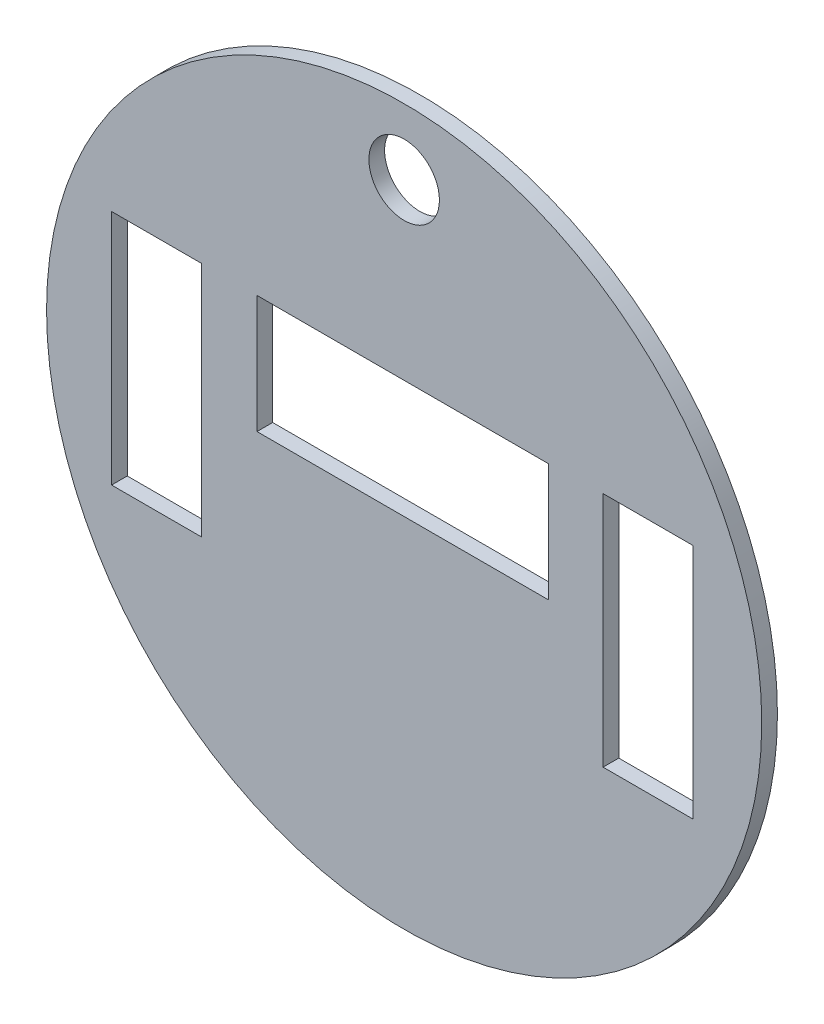
from build123d import *

# Parameters (mm, degrees)
SKETCH1_R           = 312.497780416
SKETCH1_R_2         = 30.815082176
SKETCH1_W           = 78.780158854
SKETCH1_H           = 207.033394325
SKETCH1_H_2         = 207.033394324
SKETCH1_W_2         = 254.787899309
SKETCH1_H_3         = 103.031623715
BOSS_EXTRUDE1_DEPTH = 13.716


with BuildPart() as part:
    # Sketch1 → Boss-Extrude1 (new body)
    with BuildSketch(Plane.XY):
        Circle(SKETCH1_R)
        with Locations((0, 254.843469114)):
            Circle(SKETCH1_R_2, mode=Mode.SUBTRACT)
        with Locations((213.217227107, 0.764216519)):
            Rectangle(SKETCH1_W, SKETCH1_H, mode=Mode.SUBTRACT)
        with Locations((-216.277951012, -0.485073447)):
            Rectangle(SKETCH1_W, SKETCH1_H_2, mode=Mode.SUBTRACT)
        with Locations((-1.212629894, 51.515811858)):
            Rectangle(SKETCH1_W_2, SKETCH1_H_3, mode=Mode.SUBTRACT)
    extrude(amount=BOSS_EXTRUDE1_DEPTH)


solid = part.part
